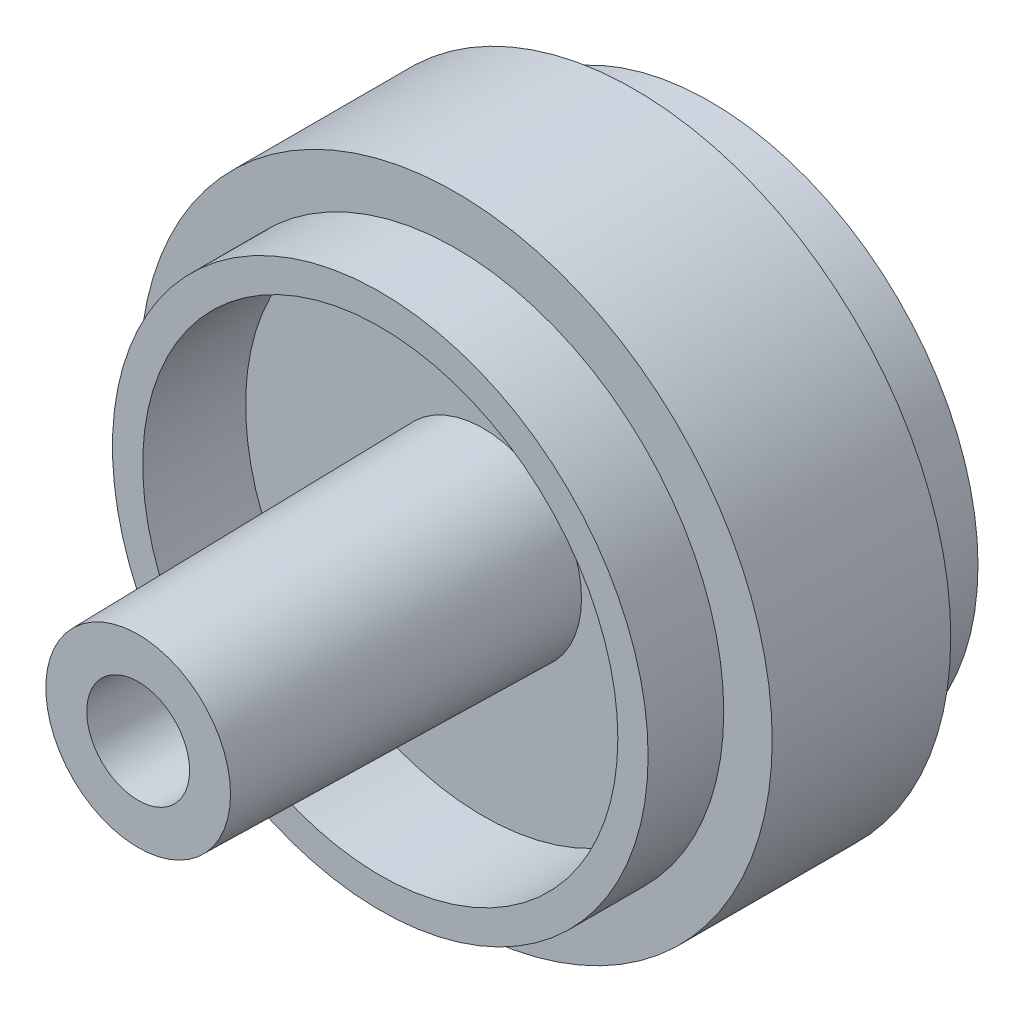
from build123d import *

# Parameters (mm, degrees)
SKETCH3_R                     = 3.25
SKETCH3_R_2                   = 1.5
BOSS_EXTRUDE2_DEPTH           = 11.4
BOSS_EXTRUDE2_TAPER           = 1
BOSS_EXTRUDE2_OTHER_WAY_DEPTH = 1


with BuildPart() as part:
    # Sketch2 → Revolve2 (revolve)
    with BuildSketch(Plane(origin=(0, 0, 0), x_dir=(0, 0, -1), z_dir=(1, 0, 0))):
        Polygon((-2.05, 3.25), (5.45, 3.25), (5.45, 4.25), (2.05, 4.25), (2.05, 7.85), (5.45, 7.85), (5.45, 8.85), (2.95, 8.85), (2.95, 10.45), (-2.95, 10.45), (-2.95, 8.85), (-5.45, 8.85), (-5.45, 7.85), (-2.05, 7.85), align=None)
    revolve(axis=Axis((0, 0, 8.833851455), (0, 0, -1)))

    # Sketch3 → Boss-Extrude2 (add)
    with BuildSketch(Plane.XY.offset(2.05)):
        Circle(SKETCH3_R)
        Circle(SKETCH3_R_2, mode=Mode.SUBTRACT)
    extrude(amount=BOSS_EXTRUDE2_DEPTH, taper=BOSS_EXTRUDE2_TAPER)

    # Sketch3 → Boss-Extrude2 other way (add)
    with BuildSketch(Plane.XY.offset(2.05)):
        Circle(SKETCH3_R)
        Circle(SKETCH3_R_2, mode=Mode.SUBTRACT)
    extrude(amount=-BOSS_EXTRUDE2_OTHER_WAY_DEPTH)


solid = part.part
